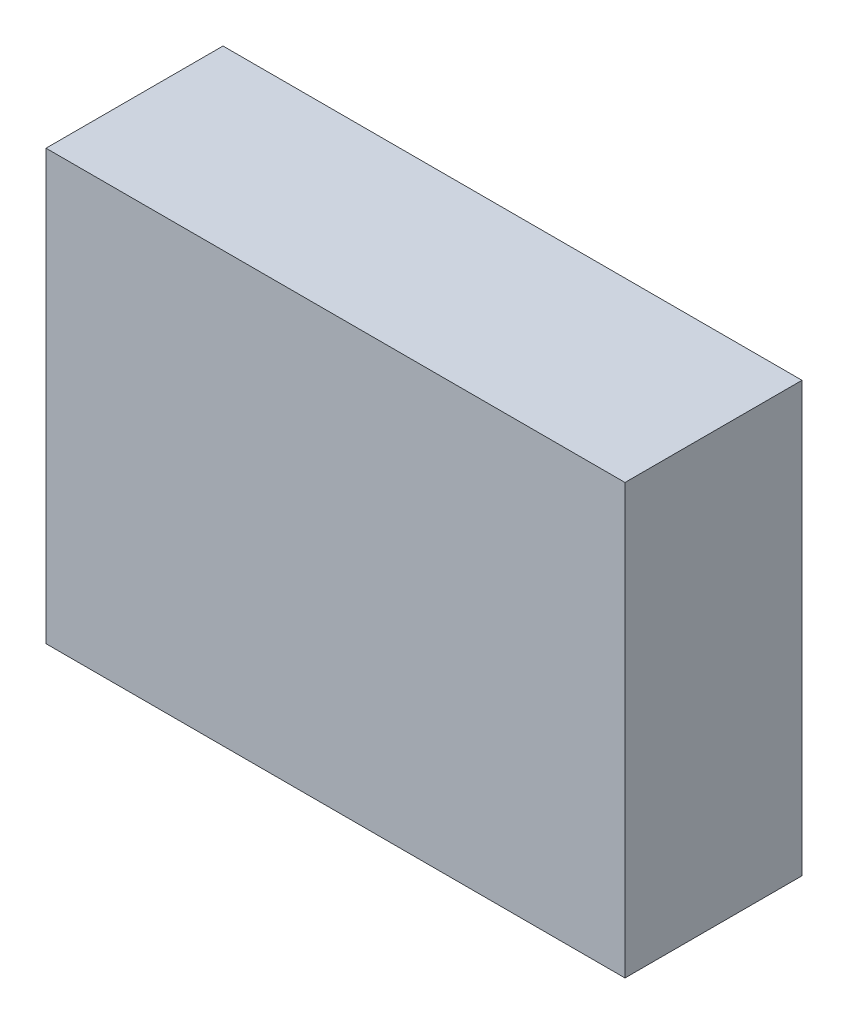
from build123d import *

# Parameters (mm, degrees)
SKETCH1_W           = 49.068252072
SKETCH1_H           = 36.368233888
BOSS_EXTRUDE1_DEPTH = 15


with BuildPart() as part:
    # Sketch1 → Boss-Extrude1 (new body)
    with BuildSketch(Plane.XY):
        with Locations((24.534126036, 18.184116944)):
            Rectangle(SKETCH1_W, SKETCH1_H)
    extrude(amount=BOSS_EXTRUDE1_DEPTH)


solid = part.part
